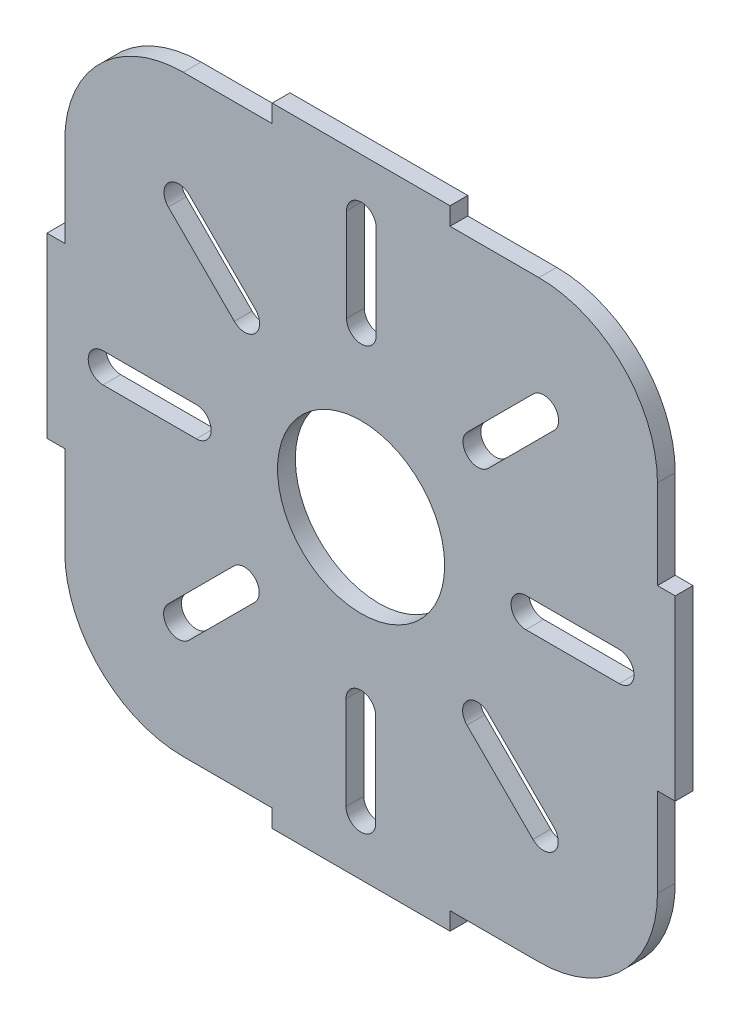
from build123d import *

# Parameters (mm, degrees)
BOSS_EXTRU_1_DEPTH           = 3
ESQUISSE2_R                  = 14.1
ENL_V_MAT_EXTRU_1_DEPTH      = 3
CONG_1_R                     = 20
ENL_V_MAT_EXTRU_2_DEPTH      = 3
R_P_TITION_CIRCULAIRE1_COUNT = 8


with BuildPart() as part:
    # Esquisse1 → Boss.-Extru.1 (new body)
    with BuildSketch(Plane.XY):
        Polygon((0, 0), (0, 35), (-3, 35), (-3, 65), (0, 65), (0, 100), (35, 100), (35, 103), (65, 103), (65, 100), (100, 100), (100, 65), (103, 65), (103, 35), (100, 35), (100, 0), (65, 0), (65, -3), (35, -3), (35, 0), align=None)
    extrude(amount=BOSS_EXTRU_1_DEPTH)

    # Esquisse2 → Enlèv. mat.-Extru.1 (cut)
    with BuildSketch(Plane.XY.offset(3)):
        with Locations((50, 50)):
            Circle(ESQUISSE2_R)
    extrude(amount=-ENL_V_MAT_EXTRU_1_DEPTH, mode=Mode.SUBTRACT)

    # Congé1
    cong_1_edges = [part.edges().sort_by_distance(p)[0] for p in [
        (0, 0, 1.5),
        (0, 100, 1.5),
        (100, 100, 1.5),
        (100, 0, 1.5),
    ]]
    fillet(cong_1_edges, radius=CONG_1_R)

    # Esquisse4 → Enlèv. mat.-Extru.2 (cut)
    with BuildSketch(Plane.XY.offset(3)):
        with BuildLine():
            Line((52.544857736, 93.542670146), (52.544857736, 77.800875632))
            ThreePointArc((52.544857736, 77.800875632), (50.044857736, 75.300875632), (47.544857736, 77.800875632))
            Line((47.544857736, 77.800875632), (47.544857736, 93.542670146))
            ThreePointArc((47.544857736, 93.542670146), (50.044857736, 96.042670146), (52.544857736, 93.542670146))
        make_face()
    enl_v_mat_extru_2 = extrude(amount=-ENL_V_MAT_EXTRU_2_DEPTH, mode=Mode.SUBTRACT)

    # Répétition circulaire1: Enlèv. mat.-Extru.2 ×8 about axis
    r_p_tition_circulaire1_axis = Axis((50, 50, 0), (0, 0, 1))
    for i in range(1, R_P_TITION_CIRCULAIRE1_COUNT):
        add(enl_v_mat_extru_2.rotate(r_p_tition_circulaire1_axis, i * 360 / R_P_TITION_CIRCULAIRE1_COUNT), mode=Mode.SUBTRACT)


solid = part.part
